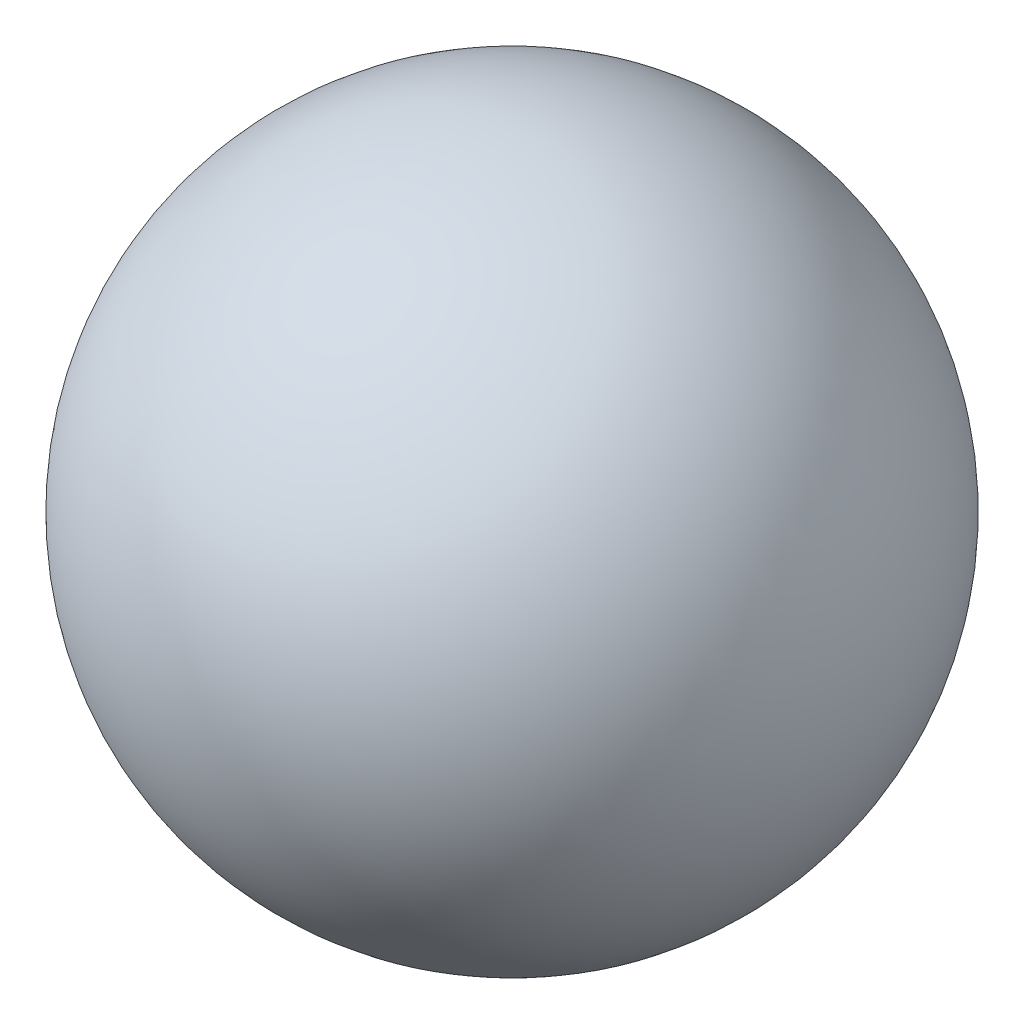
from build123d import *


with BuildPart() as part:
    # Skizze1 → Rotation1 (revolve)
    with BuildSketch(Plane.XY):
        with BuildLine():
            ThreePointArc((0, 120), (120, 0), (0, -120))
            Line((0, -120), (0, 120))
        make_face()
    revolve(axis=Axis((0, 120, 0), (0, -1, 0)))


solid = part.part
